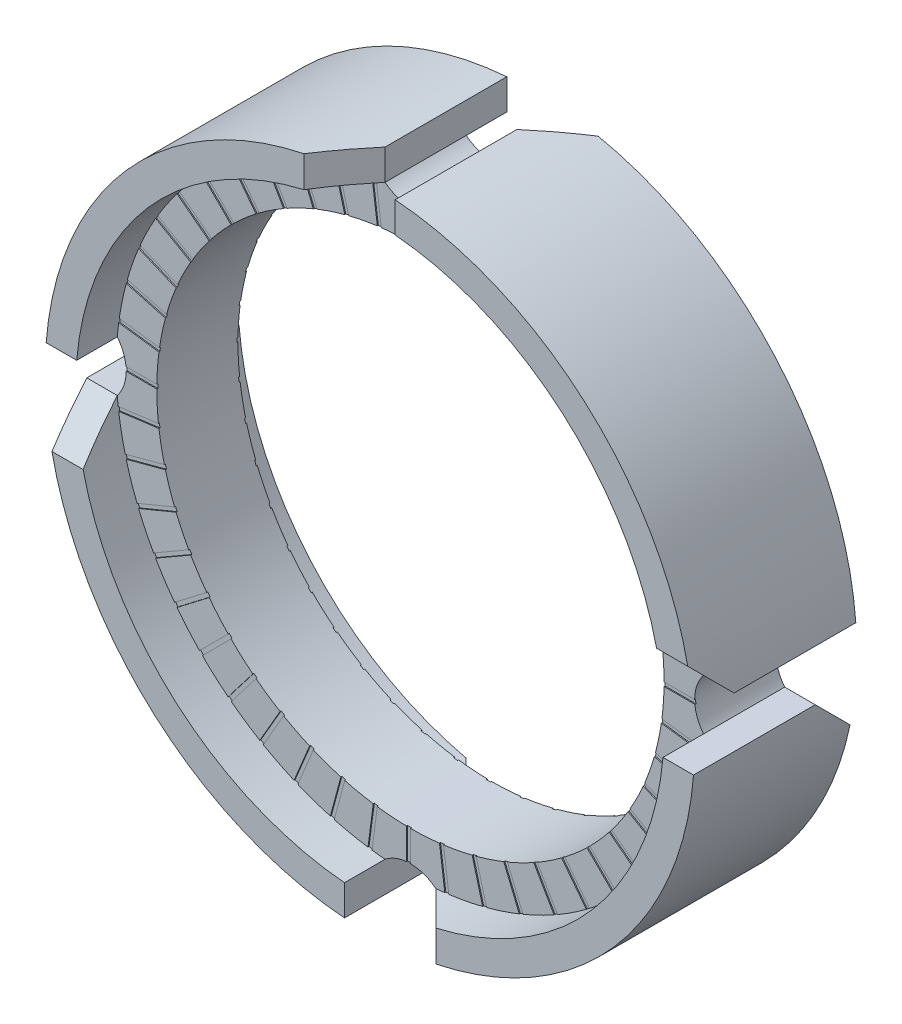
from build123d import *

# Parameters (mm, degrees)
SKETCH1_R             = 14.5
SKETCH1_R_2           = 12.5
EXTRUDE1_DEPTH        = 4
CUT_EXTRUDE1_START    = -0.05
CUT_EXTRUDE1_DEPTH    = 0.05
CIRPATTERN1_COUNT     = 48
MIRROR1_START         = -0.05
MIRROR1_COPY_1_DEPTH  = 0.05
MIRROR1_COPY_2_DEPTH  = 0.05
MIRROR1_COPY_3_DEPTH  = 0.05
MIRROR1_COPY_4_DEPTH  = 0.05
MIRROR1_COPY_5_DEPTH  = 0.05
MIRROR1_COPY_6_DEPTH  = 0.05
MIRROR1_COPY_7_DEPTH  = 0.05
MIRROR1_COPY_8_DEPTH  = 0.05
MIRROR1_COPY_9_DEPTH  = 0.05
MIRROR1_COPY_10_DEPTH = 0.05
MIRROR1_COPY_11_DEPTH = 0.05
MIRROR1_COPY_12_DEPTH = 0.05
MIRROR1_COPY_13_DEPTH = 0.05
MIRROR1_COPY_14_DEPTH = 0.05
MIRROR1_COPY_15_DEPTH = 0.05
MIRROR1_COPY_16_DEPTH = 0.05
MIRROR1_COPY_17_DEPTH = 0.05
MIRROR1_COPY_18_DEPTH = 0.05
MIRROR1_COPY_19_DEPTH = 0.05
MIRROR1_COPY_20_DEPTH = 0.05
MIRROR1_COPY_21_DEPTH = 0.05
MIRROR1_COPY_22_DEPTH = 0.05
MIRROR1_COPY_23_DEPTH = 0.05
MIRROR1_COPY_24_DEPTH = 0.05
MIRROR1_COPY_25_DEPTH = 0.05
MIRROR1_COPY_26_DEPTH = 0.05
MIRROR1_COPY_27_DEPTH = 0.05
MIRROR1_COPY_28_DEPTH = 0.05
MIRROR1_COPY_29_DEPTH = 0.05
MIRROR1_COPY_30_DEPTH = 0.05
MIRROR1_COPY_31_DEPTH = 0.05
MIRROR1_COPY_32_DEPTH = 0.05
MIRROR1_COPY_33_DEPTH = 0.05
MIRROR1_COPY_34_DEPTH = 0.05
MIRROR1_COPY_35_DEPTH = 0.05
MIRROR1_COPY_36_DEPTH = 0.05
MIRROR1_COPY_37_DEPTH = 0.05
MIRROR1_COPY_38_DEPTH = 0.05
MIRROR1_COPY_39_DEPTH = 0.05
MIRROR1_COPY_40_DEPTH = 0.05
MIRROR1_COPY_41_DEPTH = 0.05
MIRROR1_COPY_42_DEPTH = 0.05
MIRROR1_COPY_43_DEPTH = 0.05
MIRROR1_COPY_44_DEPTH = 0.05
MIRROR1_COPY_45_DEPTH = 0.05
MIRROR1_COPY_46_DEPTH = 0.05
MIRROR1_COPY_47_DEPTH = 0.05
SKETCH4_R             = 16
SKETCH4_R_2           = 14.500000000000002
EXTRUDE2_DEPTH        = 4
CUT_EXTRUDE6_DEPTH    = 25
CUT_EXTRUDE7_DEPTH    = 24.409399821439255
CUT_EXTRUDE9_DEPTH    = 24.409399821439305
CIRPATTERN2_COUNT     = 4


with BuildPart() as part:
    # Sketch1 → Extrude1 (new body)
    with BuildSketch(Plane.XY):
        Circle(SKETCH1_R)
        Circle(SKETCH1_R_2, mode=Mode.SUBTRACT)
    extrude(amount=EXTRUDE1_DEPTH)

    # Sketch2 → Cut-Extrude1 (cut)
    with BuildSketch(Plane.XY.offset(4).offset(CUT_EXTRUDE1_START)):
        with BuildLine():
            Line((-10.253048327204993, 10.253048327204885), (-8.83883476483189, 8.838834764831798))
            ThreePointArc((-8.838834764831972, 8.838834764831716), (-8.767977775798485, 8.909128224641503), (-8.696561775103293, 8.978853673593989))
            Line((-8.696561775103444, 8.978853673593834), (-10.110930807247202, 10.393222705737593))
            ThreePointArc((-10.110930807247142, 10.393222705737651), (-10.182230785107977, 10.323380078191414), (-10.253048327205082, 10.253048327204795))
        make_face()
    cut_extrude1 = extrude(amount=CUT_EXTRUDE1_DEPTH, mode=Mode.SUBTRACT)

    # CirPattern1: Cut-Extrude1 ×48 about axis
    cirpattern1_axis = Axis((-5.1e-16, -3.6e-16, 0), (0, 0, 1))
    for i in range(1, CIRPATTERN1_COUNT):
        add(cut_extrude1.rotate(cirpattern1_axis, i * 360 / CIRPATTERN1_COUNT), mode=Mode.SUBTRACT)

    # Mirror1: Cut-Extrude1 across plane
    add(cut_extrude1.mirror(Plane.XY.offset(2)), mode=Mode.SUBTRACT)

    # Mirror1 copy 1 sketch → Mirror1 copy 1 (cut)
    with BuildSketch(Plane(origin=(-5e-17, 6e-17, 0), x_dir=(0.9914448613738104, 0.13052619222005157, 0), z_dir=(0, 0, -1)).offset(MIRROR1_START)):
        with BuildLine():
            Line((-10.253048327204993, -10.253048327204885), (-8.83883476483189, -8.838834764831798))
            ThreePointArc((-8.838834764831972, -8.838834764831716), (-8.767977775798485, -8.909128224641503), (-8.696561775103293, -8.978853673593989))
            Line((-8.696561775103444, -8.978853673593834), (-10.110930807247202, -10.393222705737593))
            ThreePointArc((-10.110930807247142, -10.393222705737651), (-10.182230785107977, -10.323380078191414), (-10.253048327205082, -10.253048327204795))
        make_face()
    extrude(amount=MIRROR1_COPY_1_DEPTH, mode=Mode.SUBTRACT)

    # Mirror1 copy 2 sketch → Mirror1 copy 2 (cut)
    with BuildSketch(Plane(origin=(-1.1e-16, 1.2e-16, 0), x_dir=(0.9659258262890683, 0.25881904510252074, 0), z_dir=(0, 0, -1)).offset(MIRROR1_START)):
        with BuildLine():
            Line((-10.253048327204993, -10.253048327204885), (-8.83883476483189, -8.838834764831798))
            ThreePointArc((-8.838834764831972, -8.838834764831716), (-8.767977775798485, -8.909128224641503), (-8.696561775103293, -8.978853673593989))
            Line((-8.696561775103444, -8.978853673593834), (-10.110930807247202, -10.393222705737593))
            ThreePointArc((-10.110930807247142, -10.393222705737651), (-10.182230785107977, -10.323380078191414), (-10.253048327205082, -10.253048327204795))
        make_face()
    extrude(amount=MIRROR1_COPY_2_DEPTH, mode=Mode.SUBTRACT)

    # Mirror1 copy 3 sketch → Mirror1 copy 3 (cut)
    with BuildSketch(Plane(origin=(-1.7e-16, 1.7e-16, 0), x_dir=(0.9238795325112867, 0.3826834323650898, 0), z_dir=(0, 0, -1)).offset(MIRROR1_START)):
        with BuildLine():
            Line((-10.253048327204993, -10.253048327204885), (-8.83883476483189, -8.838834764831798))
            ThreePointArc((-8.838834764831972, -8.838834764831716), (-8.767977775798485, -8.909128224641503), (-8.696561775103293, -8.978853673593989))
            Line((-8.696561775103444, -8.978853673593834), (-10.110930807247202, -10.393222705737593))
            ThreePointArc((-10.110930807247142, -10.393222705737651), (-10.182230785107977, -10.323380078191414), (-10.253048327205082, -10.253048327204795))
        make_face()
    extrude(amount=MIRROR1_COPY_3_DEPTH, mode=Mode.SUBTRACT)

    # Mirror1 copy 4 sketch → Mirror1 copy 4 (cut)
    with BuildSketch(Plane(origin=(-2.5e-16, 2.1e-16, 0), x_dir=(0.8660254037844387, 0.49999999999999994, 0), z_dir=(0, 0, -1)).offset(MIRROR1_START)):
        with BuildLine():
            Line((-10.253048327204993, -10.253048327204885), (-8.83883476483189, -8.838834764831798))
            ThreePointArc((-8.838834764831972, -8.838834764831716), (-8.767977775798485, -8.909128224641503), (-8.696561775103293, -8.978853673593989))
            Line((-8.696561775103444, -8.978853673593834), (-10.110930807247202, -10.393222705737593))
            ThreePointArc((-10.110930807247142, -10.393222705737651), (-10.182230785107977, -10.323380078191414), (-10.253048327205082, -10.253048327204795))
        make_face()
    extrude(amount=MIRROR1_COPY_4_DEPTH, mode=Mode.SUBTRACT)

    # Mirror1 copy 5 sketch → Mirror1 copy 5 (cut)
    with BuildSketch(Plane(origin=(-3.2e-16, 2.4e-16, 0), x_dir=(0.7933533402912352, 0.6087614290087207, 0), z_dir=(0, 0, -1)).offset(MIRROR1_START)):
        with BuildLine():
            Line((-10.253048327204993, -10.253048327204885), (-8.83883476483189, -8.838834764831798))
            ThreePointArc((-8.838834764831972, -8.838834764831716), (-8.767977775798485, -8.909128224641503), (-8.696561775103293, -8.978853673593989))
            Line((-8.696561775103444, -8.978853673593834), (-10.110930807247202, -10.393222705737593))
            ThreePointArc((-10.110930807247142, -10.393222705737651), (-10.182230785107977, -10.323380078191414), (-10.253048327205082, -10.253048327204795))
        make_face()
    extrude(amount=MIRROR1_COPY_5_DEPTH, mode=Mode.SUBTRACT)

    # Mirror1 copy 6 sketch → Mirror1 copy 6 (cut)
    with BuildSketch(Plane(origin=(-4e-16, 2.6e-16, 0), x_dir=(0.7071067811865476, 0.7071067811865475, 0), z_dir=(0, 0, -1)).offset(MIRROR1_START)):
        with BuildLine():
            Line((-10.253048327204993, -10.253048327204885), (-8.83883476483189, -8.838834764831798))
            ThreePointArc((-8.838834764831972, -8.838834764831716), (-8.767977775798485, -8.909128224641503), (-8.696561775103293, -8.978853673593989))
            Line((-8.696561775103444, -8.978853673593834), (-10.110930807247202, -10.393222705737593))
            ThreePointArc((-10.110930807247142, -10.393222705737651), (-10.182230785107977, -10.323380078191414), (-10.253048327205082, -10.253048327204795))
        make_face()
    extrude(amount=MIRROR1_COPY_6_DEPTH, mode=Mode.SUBTRACT)

    # Mirror1 copy 7 sketch → Mirror1 copy 7 (cut)
    with BuildSketch(Plane(origin=(-4.8e-16, 2.7e-16, 0), x_dir=(0.6087614290087207, 0.7933533402912352, 0), z_dir=(0, 0, -1)).offset(MIRROR1_START)):
        with BuildLine():
            Line((-10.253048327204993, -10.253048327204885), (-8.83883476483189, -8.838834764831798))
            ThreePointArc((-8.838834764831972, -8.838834764831716), (-8.767977775798485, -8.909128224641503), (-8.696561775103293, -8.978853673593989))
            Line((-8.696561775103444, -8.978853673593834), (-10.110930807247202, -10.393222705737593))
            ThreePointArc((-10.110930807247142, -10.393222705737651), (-10.182230785107977, -10.323380078191414), (-10.253048327205082, -10.253048327204795))
        make_face()
    extrude(amount=MIRROR1_COPY_7_DEPTH, mode=Mode.SUBTRACT)

    # Mirror1 copy 8 sketch → Mirror1 copy 8 (cut)
    with BuildSketch(Plane(origin=(-5.6e-16, 2.7e-16, 0), x_dir=(0.5000000000000001, 0.8660254037844386, 0), z_dir=(0, 0, -1)).offset(MIRROR1_START)):
        with BuildLine():
            Line((-10.253048327204993, -10.253048327204885), (-8.83883476483189, -8.838834764831798))
            ThreePointArc((-8.838834764831972, -8.838834764831716), (-8.767977775798485, -8.909128224641503), (-8.696561775103293, -8.978853673593989))
            Line((-8.696561775103444, -8.978853673593834), (-10.110930807247202, -10.393222705737593))
            ThreePointArc((-10.110930807247142, -10.393222705737651), (-10.182230785107977, -10.323380078191414), (-10.253048327205082, -10.253048327204795))
        make_face()
    extrude(amount=MIRROR1_COPY_8_DEPTH, mode=Mode.SUBTRACT)

    # Mirror1 copy 9 sketch → Mirror1 copy 9 (cut)
    with BuildSketch(Plane(origin=(-6.4e-16, 2.5e-16, 0), x_dir=(0.38268343236508984, 0.9238795325112867, 0), z_dir=(0, 0, -1)).offset(MIRROR1_START)):
        with BuildLine():
            Line((-10.253048327204993, -10.253048327204885), (-8.83883476483189, -8.838834764831798))
            ThreePointArc((-8.838834764831972, -8.838834764831716), (-8.767977775798485, -8.909128224641503), (-8.696561775103293, -8.978853673593989))
            Line((-8.696561775103444, -8.978853673593834), (-10.110930807247202, -10.393222705737593))
            ThreePointArc((-10.110930807247142, -10.393222705737651), (-10.182230785107977, -10.323380078191414), (-10.253048327205082, -10.253048327204795))
        make_face()
    extrude(amount=MIRROR1_COPY_9_DEPTH, mode=Mode.SUBTRACT)

    # Mirror1 copy 10 sketch → Mirror1 copy 10 (cut)
    with BuildSketch(Plane(origin=(-7.2e-16, 2.3e-16, 0), x_dir=(0.25881904510252074, 0.9659258262890683, 0), z_dir=(0, 0, -1)).offset(MIRROR1_START)):
        with BuildLine():
            Line((-10.253048327204993, -10.253048327204885), (-8.83883476483189, -8.838834764831798))
            ThreePointArc((-8.838834764831972, -8.838834764831716), (-8.767977775798485, -8.909128224641503), (-8.696561775103293, -8.978853673593989))
            Line((-8.696561775103444, -8.978853673593834), (-10.110930807247202, -10.393222705737593))
            ThreePointArc((-10.110930807247142, -10.393222705737651), (-10.182230785107977, -10.323380078191414), (-10.253048327205082, -10.253048327204795))
        make_face()
    extrude(amount=MIRROR1_COPY_10_DEPTH, mode=Mode.SUBTRACT)

    # Mirror1 copy 11 sketch → Mirror1 copy 11 (cut)
    with BuildSketch(Plane(origin=(-8e-16, 2e-16, 0), x_dir=(0.1305261922200517, 0.9914448613738104, 0), z_dir=(0, 0, -1)).offset(MIRROR1_START)):
        with BuildLine():
            Line((-10.253048327204993, -10.253048327204885), (-8.83883476483189, -8.838834764831798))
            ThreePointArc((-8.838834764831972, -8.838834764831716), (-8.767977775798485, -8.909128224641503), (-8.696561775103293, -8.978853673593989))
            Line((-8.696561775103444, -8.978853673593834), (-10.110930807247202, -10.393222705737593))
            ThreePointArc((-10.110930807247142, -10.393222705737651), (-10.182230785107977, -10.323380078191414), (-10.253048327205082, -10.253048327204795))
        make_face()
    extrude(amount=MIRROR1_COPY_11_DEPTH, mode=Mode.SUBTRACT)

    # Mirror1 copy 12 sketch → Mirror1 copy 12 (cut)
    with BuildSketch(Plane.YX.offset(MIRROR1_START)):
        with BuildLine():
            Line((-10.253048327204993, -10.253048327204885), (-8.83883476483189, -8.838834764831798))
            ThreePointArc((-8.838834764831972, -8.838834764831716), (-8.767977775798485, -8.909128224641503), (-8.696561775103293, -8.978853673593989))
            Line((-8.696561775103444, -8.978853673593834), (-10.110930807247202, -10.393222705737593))
            ThreePointArc((-10.110930807247142, -10.393222705737651), (-10.182230785107977, -10.323380078191414), (-10.253048327205082, -10.253048327204795))
        make_face()
    extrude(amount=MIRROR1_COPY_12_DEPTH, mode=Mode.SUBTRACT)

    # Mirror1 copy 13 sketch → Mirror1 copy 13 (cut)
    with BuildSketch(Plane(origin=(-9.3e-16, 1.1e-16, 0), x_dir=(-0.1305261922200516, 0.9914448613738104, 0), z_dir=(0, 0, -1)).offset(MIRROR1_START)):
        with BuildLine():
            Line((-10.253048327204993, -10.253048327204885), (-8.83883476483189, -8.838834764831798))
            ThreePointArc((-8.838834764831972, -8.838834764831716), (-8.767977775798485, -8.909128224641503), (-8.696561775103293, -8.978853673593989))
            Line((-8.696561775103444, -8.978853673593834), (-10.110930807247202, -10.393222705737593))
            ThreePointArc((-10.110930807247142, -10.393222705737651), (-10.182230785107977, -10.323380078191414), (-10.253048327205082, -10.253048327204795))
        make_face()
    extrude(amount=MIRROR1_COPY_13_DEPTH, mode=Mode.SUBTRACT)

    # Mirror1 copy 14 sketch → Mirror1 copy 14 (cut)
    with BuildSketch(Plane(origin=(-9.9e-16, 5e-17, 4.4e-16), x_dir=(-0.25881904510252085, 0.9659258262890683, 0), z_dir=(0, 0, -0.9999999999999999)).offset(MIRROR1_START)):
        with BuildLine():
            Line((-10.253048327204993, -10.253048327204885), (-8.83883476483189, -8.838834764831798))
            ThreePointArc((-8.838834764831972, -8.838834764831716), (-8.767977775798485, -8.909128224641503), (-8.696561775103293, -8.978853673593989))
            Line((-8.696561775103444, -8.978853673593834), (-10.110930807247202, -10.393222705737593))
            ThreePointArc((-10.110930807247142, -10.393222705737651), (-10.182230785107977, -10.323380078191414), (-10.253048327205082, -10.253048327204795))
        make_face()
    extrude(amount=MIRROR1_COPY_14_DEPTH, mode=Mode.SUBTRACT)

    # Mirror1 copy 15 sketch → Mirror1 copy 15 (cut)
    with BuildSketch(Plane(origin=(-1.04e-15, -2e-17, 4.4e-16), x_dir=(-0.3826834323650897, 0.9238795325112867, 0), z_dir=(0, 0, -0.9999999999999999)).offset(MIRROR1_START)):
        with BuildLine():
            Line((-10.253048327204993, -10.253048327204885), (-8.83883476483189, -8.838834764831798))
            ThreePointArc((-8.838834764831972, -8.838834764831716), (-8.767977775798485, -8.909128224641503), (-8.696561775103293, -8.978853673593989))
            Line((-8.696561775103444, -8.978853673593834), (-10.110930807247202, -10.393222705737593))
            ThreePointArc((-10.110930807247142, -10.393222705737651), (-10.182230785107977, -10.323380078191414), (-10.253048327205082, -10.253048327204795))
        make_face()
    extrude(amount=MIRROR1_COPY_15_DEPTH, mode=Mode.SUBTRACT)

    # Mirror1 copy 16 sketch → Mirror1 copy 16 (cut)
    with BuildSketch(Plane(origin=(-1.07e-15, -9e-17, 0), x_dir=(-0.4999999999999998, 0.8660254037844387, 0), z_dir=(0, 0, -1)).offset(MIRROR1_START)):
        with BuildLine():
            Line((-10.253048327204993, -10.253048327204885), (-8.83883476483189, -8.838834764831798))
            ThreePointArc((-8.838834764831972, -8.838834764831716), (-8.767977775798485, -8.909128224641503), (-8.696561775103293, -8.978853673593989))
            Line((-8.696561775103444, -8.978853673593834), (-10.110930807247202, -10.393222705737593))
            ThreePointArc((-10.110930807247142, -10.393222705737651), (-10.182230785107977, -10.323380078191414), (-10.253048327205082, -10.253048327204795))
        make_face()
    extrude(amount=MIRROR1_COPY_16_DEPTH, mode=Mode.SUBTRACT)

    # Mirror1 copy 17 sketch → Mirror1 copy 17 (cut)
    with BuildSketch(Plane(origin=(-1.1e-15, -1.7e-16, 0), x_dir=(-0.6087614290087207, 0.7933533402912352, 0), z_dir=(0, 0, -1)).offset(MIRROR1_START)):
        with BuildLine():
            Line((-10.253048327204993, -10.253048327204885), (-8.83883476483189, -8.838834764831798))
            ThreePointArc((-8.838834764831972, -8.838834764831716), (-8.767977775798485, -8.909128224641503), (-8.696561775103293, -8.978853673593989))
            Line((-8.696561775103444, -8.978853673593834), (-10.110930807247202, -10.393222705737593))
            ThreePointArc((-10.110930807247142, -10.393222705737651), (-10.182230785107977, -10.323380078191414), (-10.253048327205082, -10.253048327204795))
        make_face()
    extrude(amount=MIRROR1_COPY_17_DEPTH, mode=Mode.SUBTRACT)

    # Mirror1 copy 18 sketch → Mirror1 copy 18 (cut)
    with BuildSketch(Plane(origin=(-1.12e-15, -2.4e-16, 0), x_dir=(-0.7071067811865475, 0.7071067811865476, 0), z_dir=(0, 0, -1)).offset(MIRROR1_START)):
        with BuildLine():
            Line((-10.253048327204993, -10.253048327204885), (-8.83883476483189, -8.838834764831798))
            ThreePointArc((-8.838834764831972, -8.838834764831716), (-8.767977775798485, -8.909128224641503), (-8.696561775103293, -8.978853673593989))
            Line((-8.696561775103444, -8.978853673593834), (-10.110930807247202, -10.393222705737593))
            ThreePointArc((-10.110930807247142, -10.393222705737651), (-10.182230785107977, -10.323380078191414), (-10.253048327205082, -10.253048327204795))
        make_face()
    extrude(amount=MIRROR1_COPY_18_DEPTH, mode=Mode.SUBTRACT)

    # Mirror1 copy 19 sketch → Mirror1 copy 19 (cut)
    with BuildSketch(Plane(origin=(-1.13e-15, -3.3e-16, 4.4e-16), x_dir=(-0.793353340291235, 0.6087614290087209, 0), z_dir=(0, 0, -0.9999999999999999)).offset(MIRROR1_START)):
        with BuildLine():
            Line((-10.253048327204993, -10.253048327204885), (-8.83883476483189, -8.838834764831798))
            ThreePointArc((-8.838834764831972, -8.838834764831716), (-8.767977775798485, -8.909128224641503), (-8.696561775103293, -8.978853673593989))
            Line((-8.696561775103444, -8.978853673593834), (-10.110930807247202, -10.393222705737593))
            ThreePointArc((-10.110930807247142, -10.393222705737651), (-10.182230785107977, -10.323380078191414), (-10.253048327205082, -10.253048327204795))
        make_face()
    extrude(amount=MIRROR1_COPY_19_DEPTH, mode=Mode.SUBTRACT)

    # Mirror1 copy 20 sketch → Mirror1 copy 20 (cut)
    with BuildSketch(Plane(origin=(-1.13e-15, -4.1e-16, 0), x_dir=(-0.8660254037844387, 0.49999999999999994, 0), z_dir=(0, 0, -1)).offset(MIRROR1_START)):
        with BuildLine():
            Line((-10.253048327204993, -10.253048327204885), (-8.83883476483189, -8.838834764831798))
            ThreePointArc((-8.838834764831972, -8.838834764831716), (-8.767977775798485, -8.909128224641503), (-8.696561775103293, -8.978853673593989))
            Line((-8.696561775103444, -8.978853673593834), (-10.110930807247202, -10.393222705737593))
            ThreePointArc((-10.110930807247142, -10.393222705737651), (-10.182230785107977, -10.323380078191414), (-10.253048327205082, -10.253048327204795))
        make_face()
    extrude(amount=MIRROR1_COPY_20_DEPTH, mode=Mode.SUBTRACT)

    # Mirror1 copy 21 sketch → Mirror1 copy 21 (cut)
    with BuildSketch(Plane(origin=(-1.12e-15, -4.9e-16, 0), x_dir=(-0.9238795325112867, 0.3826834323650899, 0), z_dir=(0, 0, -1)).offset(MIRROR1_START)):
        with BuildLine():
            Line((-10.253048327204993, -10.253048327204885), (-8.83883476483189, -8.838834764831798))
            ThreePointArc((-8.838834764831972, -8.838834764831716), (-8.767977775798485, -8.909128224641503), (-8.696561775103293, -8.978853673593989))
            Line((-8.696561775103444, -8.978853673593834), (-10.110930807247202, -10.393222705737593))
            ThreePointArc((-10.110930807247142, -10.393222705737651), (-10.182230785107977, -10.323380078191414), (-10.253048327205082, -10.253048327204795))
        make_face()
    extrude(amount=MIRROR1_COPY_21_DEPTH, mode=Mode.SUBTRACT)

    # Mirror1 copy 22 sketch → Mirror1 copy 22 (cut)
    with BuildSketch(Plane(origin=(-1.1e-15, -5.7e-16, 0), x_dir=(-0.9659258262890682, 0.258819045102521, 0), z_dir=(0, 0, -1)).offset(MIRROR1_START)):
        with BuildLine():
            Line((-10.253048327204993, -10.253048327204885), (-8.83883476483189, -8.838834764831798))
            ThreePointArc((-8.838834764831972, -8.838834764831716), (-8.767977775798485, -8.909128224641503), (-8.696561775103293, -8.978853673593989))
            Line((-8.696561775103444, -8.978853673593834), (-10.110930807247202, -10.393222705737593))
            ThreePointArc((-10.110930807247142, -10.393222705737651), (-10.182230785107977, -10.323380078191414), (-10.253048327205082, -10.253048327204795))
        make_face()
    extrude(amount=MIRROR1_COPY_22_DEPTH, mode=Mode.SUBTRACT)

    # Mirror1 copy 23 sketch → Mirror1 copy 23 (cut)
    with BuildSketch(Plane(origin=(-1.06e-15, -6.4e-16, 0), x_dir=(-0.9914448613738104, 0.13052619222005157, 0), z_dir=(0, 0, -1)).offset(MIRROR1_START)):
        with BuildLine():
            Line((-10.253048327204993, -10.253048327204885), (-8.83883476483189, -8.838834764831798))
            ThreePointArc((-8.838834764831972, -8.838834764831716), (-8.767977775798485, -8.909128224641503), (-8.696561775103293, -8.978853673593989))
            Line((-8.696561775103444, -8.978853673593834), (-10.110930807247202, -10.393222705737593))
            ThreePointArc((-10.110930807247142, -10.393222705737651), (-10.182230785107977, -10.323380078191414), (-10.253048327205082, -10.253048327204795))
        make_face()
    extrude(amount=MIRROR1_COPY_23_DEPTH, mode=Mode.SUBTRACT)

    # Mirror1 copy 24 sketch → Mirror1 copy 24 (cut)
    with BuildSketch(Plane(origin=(-1.02e-15, -7.1e-16, 0), x_dir=(-1, 1.2e-16, 0), z_dir=(0, 0, -1)).offset(MIRROR1_START)):
        with BuildLine():
            Line((-10.253048327204993, -10.253048327204885), (-8.83883476483189, -8.838834764831798))
            ThreePointArc((-8.838834764831972, -8.838834764831716), (-8.767977775798485, -8.909128224641503), (-8.696561775103293, -8.978853673593989))
            Line((-8.696561775103444, -8.978853673593834), (-10.110930807247202, -10.393222705737593))
            ThreePointArc((-10.110930807247142, -10.393222705737651), (-10.182230785107977, -10.323380078191414), (-10.253048327205082, -10.253048327204795))
        make_face()
    extrude(amount=MIRROR1_COPY_24_DEPTH, mode=Mode.SUBTRACT)

    # Mirror1 copy 25 sketch → Mirror1 copy 25 (cut)
    with BuildSketch(Plane(origin=(-9.7e-16, -7.7e-16, 0), x_dir=(-0.9914448613738105, -0.13052619222005132, 0), z_dir=(0, 0, -1)).offset(MIRROR1_START)):
        with BuildLine():
            Line((-10.253048327204993, -10.253048327204885), (-8.83883476483189, -8.838834764831798))
            ThreePointArc((-8.838834764831972, -8.838834764831716), (-8.767977775798485, -8.909128224641503), (-8.696561775103293, -8.978853673593989))
            Line((-8.696561775103444, -8.978853673593834), (-10.110930807247202, -10.393222705737593))
            ThreePointArc((-10.110930807247142, -10.393222705737651), (-10.182230785107977, -10.323380078191414), (-10.253048327205082, -10.253048327204795))
        make_face()
    extrude(amount=MIRROR1_COPY_25_DEPTH, mode=Mode.SUBTRACT)

    # Mirror1 copy 26 sketch → Mirror1 copy 26 (cut)
    with BuildSketch(Plane(origin=(-9.1e-16, -8.3e-16, 4.4e-16), x_dir=(-0.9659258262890683, -0.2588190451025208, 0), z_dir=(0, 0, -0.9999999999999999)).offset(MIRROR1_START)):
        with BuildLine():
            Line((-10.253048327204993, -10.253048327204885), (-8.83883476483189, -8.838834764831798))
            ThreePointArc((-8.838834764831972, -8.838834764831716), (-8.767977775798485, -8.909128224641503), (-8.696561775103293, -8.978853673593989))
            Line((-8.696561775103444, -8.978853673593834), (-10.110930807247202, -10.393222705737593))
            ThreePointArc((-10.110930807247142, -10.393222705737651), (-10.182230785107977, -10.323380078191414), (-10.253048327205082, -10.253048327204795))
        make_face()
    extrude(amount=MIRROR1_COPY_26_DEPTH, mode=Mode.SUBTRACT)

    # Mirror1 copy 27 sketch → Mirror1 copy 27 (cut)
    with BuildSketch(Plane(origin=(-8.5e-16, -8.8e-16, 0), x_dir=(-0.9238795325112868, -0.38268343236508967, 0), z_dir=(0, 0, -1)).offset(MIRROR1_START)):
        with BuildLine():
            Line((-10.253048327204993, -10.253048327204885), (-8.83883476483189, -8.838834764831798))
            ThreePointArc((-8.838834764831972, -8.838834764831716), (-8.767977775798485, -8.909128224641503), (-8.696561775103293, -8.978853673593989))
            Line((-8.696561775103444, -8.978853673593834), (-10.110930807247202, -10.393222705737593))
            ThreePointArc((-10.110930807247142, -10.393222705737651), (-10.182230785107977, -10.323380078191414), (-10.253048327205082, -10.253048327204795))
        make_face()
    extrude(amount=MIRROR1_COPY_27_DEPTH, mode=Mode.SUBTRACT)

    # Mirror1 copy 28 sketch → Mirror1 copy 28 (cut)
    with BuildSketch(Plane(origin=(-7.8e-16, -9.2e-16, 0), x_dir=(-0.8660254037844386, -0.5000000000000001, 0), z_dir=(0, 0, -1)).offset(MIRROR1_START)):
        with BuildLine():
            Line((-10.253048327204993, -10.253048327204885), (-8.83883476483189, -8.838834764831798))
            ThreePointArc((-8.838834764831972, -8.838834764831716), (-8.767977775798485, -8.909128224641503), (-8.696561775103293, -8.978853673593989))
            Line((-8.696561775103444, -8.978853673593834), (-10.110930807247202, -10.393222705737593))
            ThreePointArc((-10.110930807247142, -10.393222705737651), (-10.182230785107977, -10.323380078191414), (-10.253048327205082, -10.253048327204795))
        make_face()
    extrude(amount=MIRROR1_COPY_28_DEPTH, mode=Mode.SUBTRACT)

    # Mirror1 copy 29 sketch → Mirror1 copy 29 (cut)
    with BuildSketch(Plane(origin=(-7e-16, -9.5e-16, 0), x_dir=(-0.7933533402912352, -0.6087614290087207, 0), z_dir=(0, 0, -1)).offset(MIRROR1_START)):
        with BuildLine():
            Line((-10.253048327204993, -10.253048327204885), (-8.83883476483189, -8.838834764831798))
            ThreePointArc((-8.838834764831972, -8.838834764831716), (-8.767977775798485, -8.909128224641503), (-8.696561775103293, -8.978853673593989))
            Line((-8.696561775103444, -8.978853673593834), (-10.110930807247202, -10.393222705737593))
            ThreePointArc((-10.110930807247142, -10.393222705737651), (-10.182230785107977, -10.323380078191414), (-10.253048327205082, -10.253048327204795))
        make_face()
    extrude(amount=MIRROR1_COPY_29_DEPTH, mode=Mode.SUBTRACT)

    # Mirror1 copy 30 sketch → Mirror1 copy 30 (cut)
    with BuildSketch(Plane(origin=(-6.2e-16, -9.7e-16, 0), x_dir=(-0.7071067811865477, -0.7071067811865475, 0), z_dir=(0, 0, -1)).offset(MIRROR1_START)):
        with BuildLine():
            Line((-10.253048327204993, -10.253048327204885), (-8.83883476483189, -8.838834764831798))
            ThreePointArc((-8.838834764831972, -8.838834764831716), (-8.767977775798485, -8.909128224641503), (-8.696561775103293, -8.978853673593989))
            Line((-8.696561775103444, -8.978853673593834), (-10.110930807247202, -10.393222705737593))
            ThreePointArc((-10.110930807247142, -10.393222705737651), (-10.182230785107977, -10.323380078191414), (-10.253048327205082, -10.253048327204795))
        make_face()
    extrude(amount=MIRROR1_COPY_30_DEPTH, mode=Mode.SUBTRACT)

    # Mirror1 copy 31 sketch → Mirror1 copy 31 (cut)
    with BuildSketch(Plane(origin=(-5.4e-16, -9.8e-16, 0), x_dir=(-0.6087614290087209, -0.7933533402912349, 0), z_dir=(0, 0, -1)).offset(MIRROR1_START)):
        with BuildLine():
            Line((-10.253048327204993, -10.253048327204885), (-8.83883476483189, -8.838834764831798))
            ThreePointArc((-8.838834764831972, -8.838834764831716), (-8.767977775798485, -8.909128224641503), (-8.696561775103293, -8.978853673593989))
            Line((-8.696561775103444, -8.978853673593834), (-10.110930807247202, -10.393222705737593))
            ThreePointArc((-10.110930807247142, -10.393222705737651), (-10.182230785107977, -10.323380078191414), (-10.253048327205082, -10.253048327204795))
        make_face()
    extrude(amount=MIRROR1_COPY_31_DEPTH, mode=Mode.SUBTRACT)

    # Mirror1 copy 32 sketch → Mirror1 copy 32 (cut)
    with BuildSketch(Plane(origin=(-4.6e-16, -9.8e-16, 0), x_dir=(-0.5000000000000004, -0.8660254037844384, 0), z_dir=(0, 0, -1)).offset(MIRROR1_START)):
        with BuildLine():
            Line((-10.253048327204993, -10.253048327204885), (-8.83883476483189, -8.838834764831798))
            ThreePointArc((-8.838834764831972, -8.838834764831716), (-8.767977775798485, -8.909128224641503), (-8.696561775103293, -8.978853673593989))
            Line((-8.696561775103444, -8.978853673593834), (-10.110930807247202, -10.393222705737593))
            ThreePointArc((-10.110930807247142, -10.393222705737651), (-10.182230785107977, -10.323380078191414), (-10.253048327205082, -10.253048327204795))
        make_face()
    extrude(amount=MIRROR1_COPY_32_DEPTH, mode=Mode.SUBTRACT)

    # Mirror1 copy 33 sketch → Mirror1 copy 33 (cut)
    with BuildSketch(Plane(origin=(-3.8e-16, -9.6e-16, 0), x_dir=(-0.3826834323650895, -0.9238795325112868, 0), z_dir=(0, 0, -1)).offset(MIRROR1_START)):
        with BuildLine():
            Line((-10.253048327204993, -10.253048327204885), (-8.83883476483189, -8.838834764831798))
            ThreePointArc((-8.838834764831972, -8.838834764831716), (-8.767977775798485, -8.909128224641503), (-8.696561775103293, -8.978853673593989))
            Line((-8.696561775103444, -8.978853673593834), (-10.110930807247202, -10.393222705737593))
            ThreePointArc((-10.110930807247142, -10.393222705737651), (-10.182230785107977, -10.323380078191414), (-10.253048327205082, -10.253048327204795))
        make_face()
    extrude(amount=MIRROR1_COPY_33_DEPTH, mode=Mode.SUBTRACT)

    # Mirror1 copy 34 sketch → Mirror1 copy 34 (cut)
    with BuildSketch(Plane(origin=(-3e-16, -9.4e-16, 0), x_dir=(-0.25881904510252063, -0.9659258262890683, 0), z_dir=(0, 0, -1)).offset(MIRROR1_START)):
        with BuildLine():
            Line((-10.253048327204993, -10.253048327204885), (-8.83883476483189, -8.838834764831798))
            ThreePointArc((-8.838834764831972, -8.838834764831716), (-8.767977775798485, -8.909128224641503), (-8.696561775103293, -8.978853673593989))
            Line((-8.696561775103444, -8.978853673593834), (-10.110930807247202, -10.393222705737593))
            ThreePointArc((-10.110930807247142, -10.393222705737651), (-10.182230785107977, -10.323380078191414), (-10.253048327205082, -10.253048327204795))
        make_face()
    extrude(amount=MIRROR1_COPY_34_DEPTH, mode=Mode.SUBTRACT)

    # Mirror1 copy 35 sketch → Mirror1 copy 35 (cut)
    with BuildSketch(Plane(origin=(-2.3e-16, -9.1e-16, 0), x_dir=(-0.13052619222005163, -0.9914448613738104, 0), z_dir=(0, 0, -1)).offset(MIRROR1_START)):
        with BuildLine():
            Line((-10.253048327204993, -10.253048327204885), (-8.83883476483189, -8.838834764831798))
            ThreePointArc((-8.838834764831972, -8.838834764831716), (-8.767977775798485, -8.909128224641503), (-8.696561775103293, -8.978853673593989))
            Line((-8.696561775103444, -8.978853673593834), (-10.110930807247202, -10.393222705737593))
            ThreePointArc((-10.110930807247142, -10.393222705737651), (-10.182230785107977, -10.323380078191414), (-10.253048327205082, -10.253048327204795))
        make_face()
    extrude(amount=MIRROR1_COPY_35_DEPTH, mode=Mode.SUBTRACT)

    # Mirror1 copy 36 sketch → Mirror1 copy 36 (cut)
    with BuildSketch(Plane(origin=(-1.6e-16, -8.7e-16, 0), x_dir=(-1.8e-16, -1, 0), z_dir=(0, 0, -1)).offset(MIRROR1_START)):
        with BuildLine():
            Line((-10.253048327204993, -10.253048327204885), (-8.83883476483189, -8.838834764831798))
            ThreePointArc((-8.838834764831972, -8.838834764831716), (-8.767977775798485, -8.909128224641503), (-8.696561775103293, -8.978853673593989))
            Line((-8.696561775103444, -8.978853673593834), (-10.110930807247202, -10.393222705737593))
            ThreePointArc((-10.110930807247142, -10.393222705737651), (-10.182230785107977, -10.323380078191414), (-10.253048327205082, -10.253048327204795))
        make_face()
    extrude(amount=MIRROR1_COPY_36_DEPTH, mode=Mode.SUBTRACT)

    # Mirror1 copy 37 sketch → Mirror1 copy 37 (cut)
    with BuildSketch(Plane(origin=(-9e-17, -8.2e-16, 0), x_dir=(0.13052619222005127, -0.9914448613738105, 0), z_dir=(0, 0, -1)).offset(MIRROR1_START)):
        with BuildLine():
            Line((-10.253048327204993, -10.253048327204885), (-8.83883476483189, -8.838834764831798))
            ThreePointArc((-8.838834764831972, -8.838834764831716), (-8.767977775798485, -8.909128224641503), (-8.696561775103293, -8.978853673593989))
            Line((-8.696561775103444, -8.978853673593834), (-10.110930807247202, -10.393222705737593))
            ThreePointArc((-10.110930807247142, -10.393222705737651), (-10.182230785107977, -10.323380078191414), (-10.253048327205082, -10.253048327204795))
        make_face()
    extrude(amount=MIRROR1_COPY_37_DEPTH, mode=Mode.SUBTRACT)

    # Mirror1 copy 38 sketch → Mirror1 copy 38 (cut)
    with BuildSketch(Plane(origin=(-4e-17, -7.6e-16, 0), x_dir=(0.2588190451025203, -0.9659258262890684, 0), z_dir=(0, 0, -1)).offset(MIRROR1_START)):
        with BuildLine():
            Line((-10.253048327204993, -10.253048327204885), (-8.83883476483189, -8.838834764831798))
            ThreePointArc((-8.838834764831972, -8.838834764831716), (-8.767977775798485, -8.909128224641503), (-8.696561775103293, -8.978853673593989))
            Line((-8.696561775103444, -8.978853673593834), (-10.110930807247202, -10.393222705737593))
            ThreePointArc((-10.110930807247142, -10.393222705737651), (-10.182230785107977, -10.323380078191414), (-10.253048327205082, -10.253048327204795))
        make_face()
    extrude(amount=MIRROR1_COPY_38_DEPTH, mode=Mode.SUBTRACT)

    # Mirror1 copy 39 sketch → Mirror1 copy 39 (cut)
    with BuildSketch(Plane(origin=(1e-17, -6.9e-16, 0), x_dir=(0.38268343236509, -0.9238795325112866, 0), z_dir=(0, 0, -1)).offset(MIRROR1_START)):
        with BuildLine():
            Line((-10.253048327204993, -10.253048327204885), (-8.83883476483189, -8.838834764831798))
            ThreePointArc((-8.838834764831972, -8.838834764831716), (-8.767977775798485, -8.909128224641503), (-8.696561775103293, -8.978853673593989))
            Line((-8.696561775103444, -8.978853673593834), (-10.110930807247202, -10.393222705737593))
            ThreePointArc((-10.110930807247142, -10.393222705737651), (-10.182230785107977, -10.323380078191414), (-10.253048327205082, -10.253048327204795))
        make_face()
    extrude(amount=MIRROR1_COPY_39_DEPTH, mode=Mode.SUBTRACT)

    # Mirror1 copy 40 sketch → Mirror1 copy 40 (cut)
    with BuildSketch(Plane(origin=(5e-17, -6.2e-16, 0), x_dir=(0.5000000000000001, -0.8660254037844386, 0), z_dir=(0, 0, -1)).offset(MIRROR1_START)):
        with BuildLine():
            Line((-10.253048327204993, -10.253048327204885), (-8.83883476483189, -8.838834764831798))
            ThreePointArc((-8.838834764831972, -8.838834764831716), (-8.767977775798485, -8.909128224641503), (-8.696561775103293, -8.978853673593989))
            Line((-8.696561775103444, -8.978853673593834), (-10.110930807247202, -10.393222705737593))
            ThreePointArc((-10.110930807247142, -10.393222705737651), (-10.182230785107977, -10.323380078191414), (-10.253048327205082, -10.253048327204795))
        make_face()
    extrude(amount=MIRROR1_COPY_40_DEPTH, mode=Mode.SUBTRACT)

    # Mirror1 copy 41 sketch → Mirror1 copy 41 (cut)
    with BuildSketch(Plane(origin=(8e-17, -5.4e-16, 0), x_dir=(0.6087614290087205, -0.7933533402912352, 0), z_dir=(0, 0, -1)).offset(MIRROR1_START)):
        with BuildLine():
            Line((-10.253048327204993, -10.253048327204885), (-8.83883476483189, -8.838834764831798))
            ThreePointArc((-8.838834764831972, -8.838834764831716), (-8.767977775798485, -8.909128224641503), (-8.696561775103293, -8.978853673593989))
            Line((-8.696561775103444, -8.978853673593834), (-10.110930807247202, -10.393222705737593))
            ThreePointArc((-10.110930807247142, -10.393222705737651), (-10.182230785107977, -10.323380078191414), (-10.253048327205082, -10.253048327204795))
        make_face()
    extrude(amount=MIRROR1_COPY_41_DEPTH, mode=Mode.SUBTRACT)

    # Mirror1 copy 42 sketch → Mirror1 copy 42 (cut)
    with BuildSketch(Plane(origin=(1e-16, -4.7e-16, 0), x_dir=(0.7071067811865474, -0.7071067811865477, 0), z_dir=(0, 0, -1)).offset(MIRROR1_START)):
        with BuildLine():
            Line((-10.253048327204993, -10.253048327204885), (-8.83883476483189, -8.838834764831798))
            ThreePointArc((-8.838834764831972, -8.838834764831716), (-8.767977775798485, -8.909128224641503), (-8.696561775103293, -8.978853673593989))
            Line((-8.696561775103444, -8.978853673593834), (-10.110930807247202, -10.393222705737593))
            ThreePointArc((-10.110930807247142, -10.393222705737651), (-10.182230785107977, -10.323380078191414), (-10.253048327205082, -10.253048327204795))
        make_face()
    extrude(amount=MIRROR1_COPY_42_DEPTH, mode=Mode.SUBTRACT)

    # Mirror1 copy 43 sketch → Mirror1 copy 43 (cut)
    with BuildSketch(Plane(origin=(1.1e-16, -3.8e-16, 0), x_dir=(0.7933533402912349, -0.6087614290087209, 0), z_dir=(0, 0, -1)).offset(MIRROR1_START)):
        with BuildLine():
            Line((-10.253048327204993, -10.253048327204885), (-8.83883476483189, -8.838834764831798))
            ThreePointArc((-8.838834764831972, -8.838834764831716), (-8.767977775798485, -8.909128224641503), (-8.696561775103293, -8.978853673593989))
            Line((-8.696561775103444, -8.978853673593834), (-10.110930807247202, -10.393222705737593))
            ThreePointArc((-10.110930807247142, -10.393222705737651), (-10.182230785107977, -10.323380078191414), (-10.253048327205082, -10.253048327204795))
        make_face()
    extrude(amount=MIRROR1_COPY_43_DEPTH, mode=Mode.SUBTRACT)

    # Mirror1 copy 44 sketch → Mirror1 copy 44 (cut)
    with BuildSketch(Plane(origin=(1.1e-16, -3e-16, 0), x_dir=(0.8660254037844384, -0.5000000000000004, 0), z_dir=(0, 0, -1)).offset(MIRROR1_START)):
        with BuildLine():
            Line((-10.253048327204993, -10.253048327204885), (-8.83883476483189, -8.838834764831798))
            ThreePointArc((-8.838834764831972, -8.838834764831716), (-8.767977775798485, -8.909128224641503), (-8.696561775103293, -8.978853673593989))
            Line((-8.696561775103444, -8.978853673593834), (-10.110930807247202, -10.393222705737593))
            ThreePointArc((-10.110930807247142, -10.393222705737651), (-10.182230785107977, -10.323380078191414), (-10.253048327205082, -10.253048327204795))
        make_face()
    extrude(amount=MIRROR1_COPY_44_DEPTH, mode=Mode.SUBTRACT)

    # Mirror1 copy 45 sketch → Mirror1 copy 45 (cut)
    with BuildSketch(Plane(origin=(1e-16, -2.2e-16, 0), x_dir=(0.9238795325112868, -0.38268343236508956, 0), z_dir=(0, 0, -1)).offset(MIRROR1_START)):
        with BuildLine():
            Line((-10.253048327204993, -10.253048327204885), (-8.83883476483189, -8.838834764831798))
            ThreePointArc((-8.838834764831972, -8.838834764831716), (-8.767977775798485, -8.909128224641503), (-8.696561775103293, -8.978853673593989))
            Line((-8.696561775103444, -8.978853673593834), (-10.110930807247202, -10.393222705737593))
            ThreePointArc((-10.110930807247142, -10.393222705737651), (-10.182230785107977, -10.323380078191414), (-10.253048327205082, -10.253048327204795))
        make_face()
    extrude(amount=MIRROR1_COPY_45_DEPTH, mode=Mode.SUBTRACT)

    # Mirror1 copy 46 sketch → Mirror1 copy 46 (cut)
    with BuildSketch(Plane(origin=(7e-17, -1.4e-16, 0), x_dir=(0.9659258262890683, -0.2588190451025207, 0), z_dir=(0, 0, -1)).offset(MIRROR1_START)):
        with BuildLine():
            Line((-10.253048327204993, -10.253048327204885), (-8.83883476483189, -8.838834764831798))
            ThreePointArc((-8.838834764831972, -8.838834764831716), (-8.767977775798485, -8.909128224641503), (-8.696561775103293, -8.978853673593989))
            Line((-8.696561775103444, -8.978853673593834), (-10.110930807247202, -10.393222705737593))
            ThreePointArc((-10.110930807247142, -10.393222705737651), (-10.182230785107977, -10.323380078191414), (-10.253048327205082, -10.253048327204795))
        make_face()
    extrude(amount=MIRROR1_COPY_46_DEPTH, mode=Mode.SUBTRACT)

    # Mirror1 copy 47 sketch → Mirror1 copy 47 (cut)
    with BuildSketch(Plane(origin=(4e-17, -7e-17, 0), x_dir=(0.9914448613738104, -0.13052619222005168, 0), z_dir=(0, 0, -1)).offset(MIRROR1_START)):
        with BuildLine():
            Line((-10.253048327204993, -10.253048327204885), (-8.83883476483189, -8.838834764831798))
            ThreePointArc((-8.838834764831972, -8.838834764831716), (-8.767977775798485, -8.909128224641503), (-8.696561775103293, -8.978853673593989))
            Line((-8.696561775103444, -8.978853673593834), (-10.110930807247202, -10.393222705737593))
            ThreePointArc((-10.110930807247142, -10.393222705737651), (-10.182230785107977, -10.323380078191414), (-10.253048327205082, -10.253048327204795))
        make_face()
    extrude(amount=MIRROR1_COPY_47_DEPTH, mode=Mode.SUBTRACT)

    # Sketch4 → Extrude2 (add, symmetric)
    with BuildSketch(Plane.XY.offset(2)):
        Circle(SKETCH4_R)
        Circle(SKETCH4_R_2, mode=Mode.SUBTRACT)
    extrude(amount=EXTRUDE2_DEPTH, both=True)

    # Sketch5 → Cut-Extrude6 (cut, through all)
    with BuildSketch(Plane.XY.offset(6)):
        with BuildLine():
            Line((1.2500000000000002, 15.951097140949274), (1.2499999999999993, 14.44602021319367))
            ThreePointArc((1.2499999999999993, 14.44602021319367), (1.2e-16, 14.00726971279327), (-1.2499999999999993, 14.44602021319367))
            Line((-1.2499999999999993, 14.44602021319367), (-1.2500000000000002, 15.951097140949274))
            ThreePointArc((-1.2500000000000002, 15.951097140949274), (9.8e-16, 16.000000000000004), (1.2500000000000002, 15.951097140949274))
        make_face()
    cut_extrude6 = extrude(amount=-CUT_EXTRUDE6_DEPTH, mode=Mode.SUBTRACT)

    # Sketch6 → Cut-Extrude7 (cut, through all)
    with BuildSketch(Plane(origin=(0, 0, 0), x_dir=(1, 0, 0), z_dir=(0, 1, 0))):
        Polygon((-3.2500000000000004, -6), (-1.2500000000000002, -3.9999999999999916), (-1.2500000000000002, -6), align=None)
    cut_extrude7 = extrude(amount=CUT_EXTRUDE7_DEPTH, mode=Mode.SUBTRACT)

    # Sketch7 → Cut-Extrude9 (cut, through all)
    with BuildSketch(Plane(origin=(0, 0, 0), x_dir=(1, 0, 0), z_dir=(0, 1, 0))):
        Polygon((3.2500000000000004, 2), (1.2500000000000002, -7.37e-15), (1.2500000000000002, 2), align=None)
    cut_extrude9 = extrude(amount=CUT_EXTRUDE9_DEPTH, mode=Mode.SUBTRACT)

    # CirPattern2: Cut-Extrude6, Cut-Extrude7, Cut-Extrude9 ×4 about axis
    cirpattern2_axis = Axis((-3e-17, 3e-17, 0), (0, 0, 1))
    add([cut_extrude6.rotate(cirpattern2_axis, i * 360 / CIRPATTERN2_COUNT) for i in range(1, CIRPATTERN2_COUNT)], mode=Mode.SUBTRACT)
    add([cut_extrude7.rotate(cirpattern2_axis, i * 360 / CIRPATTERN2_COUNT) for i in range(1, CIRPATTERN2_COUNT)], mode=Mode.SUBTRACT)
    add([cut_extrude9.rotate(cirpattern2_axis, i * 360 / CIRPATTERN2_COUNT) for i in range(1, CIRPATTERN2_COUNT)], mode=Mode.SUBTRACT)


solid = part.part
